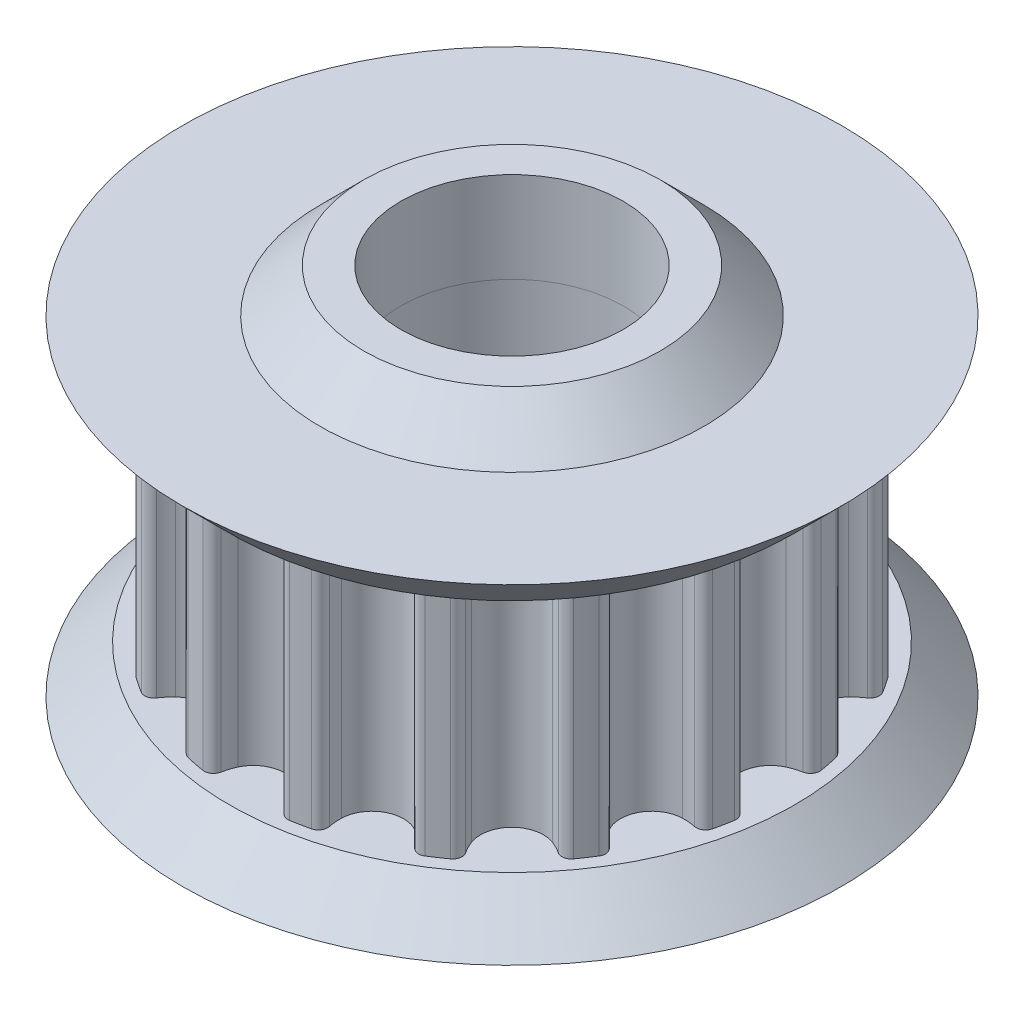
from build123d import *

# Parameters (mm, degrees)
SKETCH1_R           = 3
BOSS_EXTRUDE1_DEPTH = 3.175


with BuildPart() as part:
    # Sketch1 → Boss-Extrude1 (new body, symmetric)
    with BuildSketch(Plane(origin=(0, 0, 0), x_dir=(1, 0, 0), z_dir=(0, 1, 0))):
        with BuildLine():
            ThreePointArc((-1.850768, -6.777037356), (-1.816941892, -6.962421006), (-1.663291889, -7.071521784))
            ThreePointArc((-1.663291889, -7.071521784), (-1.417233644, -7.124914669), (-1.169472895, -7.169748489))
            ThreePointArc((-1.169472895, -7.169748489), (-0.985767742, -7.127751824), (-0.883573242, -6.969424355))
            ThreePointArc((-0.883573242, -6.969424355), (-0.839120956, -6.792881518), (-0.773880597, -6.622919538))
            ThreePointArc((-0.773880597, -6.622919538), (0, -6.1245), (0.773880597, -6.622919538))
            ThreePointArc((0.773880597, -6.622919538), (0.839120956, -6.792881518), (0.883573242, -6.969424355))
            ThreePointArc((0.883573242, -6.969424355), (0.985767742, -7.127751824), (1.169472895, -7.169748489))
            ThreePointArc((1.169472895, -7.169748489), (1.417233644, -7.124914669), (1.663291889, -7.071521784))
            ThreePointArc((1.663291889, -7.071521784), (1.816941892, -6.962421006), (1.850768, -6.777037356))
            ThreePointArc((1.850768, -6.777037356), (1.824276538, -6.596921889), (1.819509137, -6.414931089))
            ThreePointArc((1.819509137, -6.414931089), (2.343744682, -5.658300197), (3.249454025, -5.822628523))
            ThreePointArc((3.249454025, -5.822628523), (3.374769892, -5.954686513), (3.483398468, -6.100779674))
            ThreePointArc((3.483398468, -6.100779674), (3.638403174, -6.20794704), (3.824196033, -6.176445981))
            ThreePointArc((3.824196033, -6.176445981), (4.035939958, -6.040210999), (4.242835561, -5.896719991))
            ThreePointArc((4.242835561, -5.896719991), (4.343038594, -5.737124705), (4.303346591, -5.552907854))
            ThreePointArc((4.303346591, -5.552907854), (4.209944466, -5.396640704), (4.135895098, -5.230327534))
            ThreePointArc((4.135895098, -5.230327534), (4.330675481, -4.330675481), (5.230327534, -4.135895098))
            ThreePointArc((5.230327534, -4.135895098), (5.396640704, -4.209944466), (5.552907854, -4.303346591))
            ThreePointArc((5.552907854, -4.303346591), (5.737124705, -4.343038594), (5.896719991, -4.242835561))
            ThreePointArc((5.896719991, -4.242835561), (6.040210999, -4.035939958), (6.176445981, -3.824196033))
            ThreePointArc((6.176445981, -3.824196033), (6.20794704, -3.638403174), (6.100779674, -3.483398468))
            ThreePointArc((6.100779674, -3.483398468), (5.954686513, -3.374769892), (5.822628523, -3.249454025))
            ThreePointArc((5.822628523, -3.249454025), (5.658300197, -2.343744682), (6.414931089, -1.819509137))
            ThreePointArc((6.414931089, -1.819509137), (6.596921889, -1.824276538), (6.777037356, -1.850768))
            ThreePointArc((6.777037356, -1.850768), (6.962421006, -1.816941892), (7.071521784, -1.663291889))
            ThreePointArc((7.071521784, -1.663291889), (7.124914669, -1.417233644), (7.169748489, -1.169472895))
            ThreePointArc((7.169748489, -1.169472895), (7.127751824, -0.985767742), (6.969424355, -0.883573242))
            ThreePointArc((6.969424355, -0.883573242), (6.792881518, -0.839120956), (6.622919538, -0.773880597))
            ThreePointArc((6.622919538, -0.773880597), (6.1245, 0), (6.622919538, 0.773880597))
            ThreePointArc((6.622919538, 0.773880597), (6.792881518, 0.839120956), (6.969424355, 0.883573242))
            ThreePointArc((6.969424355, 0.883573242), (7.127751824, 0.985767742), (7.169748489, 1.169472895))
            ThreePointArc((7.169748489, 1.169472895), (7.124914669, 1.417233644), (7.071521784, 1.663291889))
            ThreePointArc((7.071521784, 1.663291889), (6.962421006, 1.816941892), (6.777037356, 1.850768))
            ThreePointArc((6.777037356, 1.850768), (6.596921889, 1.824276538), (6.414931089, 1.819509137))
            ThreePointArc((6.414931089, 1.819509137), (5.658300197, 2.343744682), (5.822628523, 3.249454025))
            ThreePointArc((5.822628523, 3.249454025), (5.954686513, 3.374769892), (6.100779674, 3.483398468))
            ThreePointArc((6.100779674, 3.483398468), (6.20794704, 3.638403174), (6.176445981, 3.824196033))
            ThreePointArc((6.176445981, 3.824196033), (6.040210999, 4.035939958), (5.896719991, 4.242835561))
            ThreePointArc((5.896719991, 4.242835561), (5.737124705, 4.343038594), (5.552907854, 4.303346591))
            ThreePointArc((5.552907854, 4.303346591), (5.396640704, 4.209944466), (5.230327534, 4.135895098))
            ThreePointArc((5.230327534, 4.135895098), (4.330675481, 4.330675481), (4.135895098, 5.230327534))
            ThreePointArc((4.135895098, 5.230327534), (4.209944466, 5.396640704), (4.303346591, 5.552907854))
            ThreePointArc((4.303346591, 5.552907854), (4.343038594, 5.737124705), (4.242835561, 5.896719991))
            ThreePointArc((4.242835561, 5.896719991), (4.035939958, 6.040210999), (3.824196033, 6.176445981))
            ThreePointArc((3.824196033, 6.176445981), (3.638403174, 6.20794704), (3.483398468, 6.100779674))
            ThreePointArc((3.483398468, 6.100779674), (3.374769892, 5.954686513), (3.249454025, 5.822628523))
            ThreePointArc((3.249454025, 5.822628523), (2.343744682, 5.658300197), (1.819509137, 6.414931089))
            ThreePointArc((1.819509137, 6.414931089), (1.824276538, 6.596921889), (1.850768, 6.777037356))
            ThreePointArc((1.850768, 6.777037356), (1.816941892, 6.962421006), (1.663291889, 7.071521784))
            ThreePointArc((1.663291889, 7.071521784), (1.417233644, 7.124914669), (1.169472895, 7.169748489))
            ThreePointArc((1.169472895, 7.169748489), (0.985767742, 7.127751824), (0.883573242, 6.969424355))
            ThreePointArc((0.883573242, 6.969424355), (0.839120956, 6.792881518), (0.773880597, 6.622919538))
            ThreePointArc((0.773880597, 6.622919538), (0, 6.1245), (-0.773880597, 6.622919538))
            ThreePointArc((-0.773880597, 6.622919538), (-0.839120956, 6.792881518), (-0.883573242, 6.969424355))
            ThreePointArc((-0.883573242, 6.969424355), (-0.985767742, 7.127751824), (-1.169472895, 7.169748489))
            ThreePointArc((-1.169472895, 7.169748489), (-1.417233644, 7.124914669), (-1.663291889, 7.071521784))
            ThreePointArc((-1.663291889, 7.071521784), (-1.816941892, 6.962421006), (-1.850768, 6.777037356))
            ThreePointArc((-1.850768, 6.777037356), (-1.824276538, 6.596921889), (-1.819509137, 6.414931089))
            ThreePointArc((-1.819509137, 6.414931089), (-2.343744682, 5.658300197), (-3.249454025, 5.822628523))
            ThreePointArc((-3.249454025, 5.822628523), (-3.374769892, 5.954686513), (-3.483398468, 6.100779674))
            ThreePointArc((-3.483398468, 6.100779674), (-3.638403174, 6.20794704), (-3.824196033, 6.176445981))
            ThreePointArc((-3.824196033, 6.176445981), (-4.035939958, 6.040210999), (-4.242835561, 5.896719991))
            ThreePointArc((-4.242835561, 5.896719991), (-4.343038594, 5.737124705), (-4.303346591, 5.552907854))
            ThreePointArc((-4.303346591, 5.552907854), (-4.209944466, 5.396640704), (-4.135895098, 5.230327534))
            ThreePointArc((-4.135895098, 5.230327534), (-4.330675481, 4.330675481), (-5.230327534, 4.135895098))
            ThreePointArc((-5.230327534, 4.135895098), (-5.396640704, 4.209944466), (-5.552907854, 4.303346591))
            ThreePointArc((-5.552907854, 4.303346591), (-5.737124705, 4.343038594), (-5.896719991, 4.242835561))
            ThreePointArc((-5.896719991, 4.242835561), (-6.040210999, 4.035939958), (-6.176445981, 3.824196033))
            ThreePointArc((-6.176445981, 3.824196033), (-6.20794704, 3.638403174), (-6.100779674, 3.483398468))
            ThreePointArc((-6.100779674, 3.483398468), (-5.954686513, 3.374769892), (-5.822628523, 3.249454025))
            ThreePointArc((-5.822628523, 3.249454025), (-5.658300197, 2.343744682), (-6.414931089, 1.819509137))
            ThreePointArc((-6.414931089, 1.819509137), (-6.596921889, 1.824276538), (-6.777037356, 1.850768))
            ThreePointArc((-6.777037356, 1.850768), (-6.962421006, 1.816941892), (-7.071521784, 1.663291889))
            ThreePointArc((-7.071521784, 1.663291889), (-7.124914669, 1.417233644), (-7.169748489, 1.169472895))
            ThreePointArc((-7.169748489, 1.169472895), (-7.127751824, 0.985767742), (-6.969424355, 0.883573242))
            ThreePointArc((-6.969424355, 0.883573242), (-6.792881518, 0.839120956), (-6.622919538, 0.773880597))
            ThreePointArc((-6.622919538, 0.773880597), (-6.1245, 0), (-6.622919538, -0.773880597))
            ThreePointArc((-6.622919538, -0.773880597), (-6.792881518, -0.839120956), (-6.969424355, -0.883573242))
            ThreePointArc((-6.969424355, -0.883573242), (-7.127751824, -0.985767742), (-7.169748489, -1.169472895))
            ThreePointArc((-7.169748489, -1.169472895), (-7.124914669, -1.417233644), (-7.071521784, -1.663291889))
            ThreePointArc((-7.071521784, -1.663291889), (-6.962421006, -1.816941892), (-6.777037356, -1.850768))
            ThreePointArc((-6.777037356, -1.850768), (-6.596921889, -1.824276538), (-6.414931089, -1.819509137))
            ThreePointArc((-6.414931089, -1.819509137), (-5.658300197, -2.343744682), (-5.822628523, -3.249454025))
            ThreePointArc((-5.822628523, -3.249454025), (-5.954686513, -3.374769892), (-6.100779674, -3.483398468))
            ThreePointArc((-6.100779674, -3.483398468), (-6.20794704, -3.638403174), (-6.176445981, -3.824196033))
            ThreePointArc((-6.176445981, -3.824196033), (-6.040210999, -4.035939958), (-5.896719991, -4.242835561))
            ThreePointArc((-5.896719991, -4.242835561), (-5.737124705, -4.343038594), (-5.552907854, -4.303346591))
            ThreePointArc((-5.552907854, -4.303346591), (-5.396640704, -4.209944466), (-5.230327534, -4.135895098))
            ThreePointArc((-5.230327534, -4.135895098), (-4.330675481, -4.330675481), (-4.135895098, -5.230327534))
            ThreePointArc((-4.135895098, -5.230327534), (-4.209944466, -5.396640704), (-4.303346591, -5.552907854))
            ThreePointArc((-4.303346591, -5.552907854), (-4.343038594, -5.737124705), (-4.242835561, -5.896719991))
            ThreePointArc((-4.242835561, -5.896719991), (-4.035939958, -6.040210999), (-3.824196033, -6.176445981))
            ThreePointArc((-3.824196033, -6.176445981), (-3.638403174, -6.20794704), (-3.483398468, -6.100779674))
            ThreePointArc((-3.483398468, -6.100779674), (-3.374769892, -5.954686513), (-3.249454025, -5.822628523))
            ThreePointArc((-3.249454025, -5.822628523), (-2.343744682, -5.658300197), (-1.819509137, -6.414931089))
            ThreePointArc((-1.819509137, -6.414931089), (-1.824276538, -6.596921889), (-1.850768, -6.777037356))
        make_face()
        Circle(SKETCH1_R, mode=Mode.SUBTRACT)
    extrude(amount=BOSS_EXTRUDE1_DEPTH, both=True)


with BuildPart() as body_2:
    # Sketch4 → Revolve1 (revolve)
    with BuildSketch(Plane.XY):
        Polygon((-7.62, 3.175), (-3, 3.175), (-3, 5.62102), (-4, 5.62102), (-5.17602, 4.445), (-8.89, 4.445), align=None)
        Polygon((-7.62, -3.175), (-8.89, -4.445), (-5.27, -4.445), (-4, -5.715), (-3, -5.715), (-3, -3.175), align=None)
    revolve(axis=Axis((0, 0, 0), (0, 1, 0)))


solid = Compound([part.part, body_2.part])
